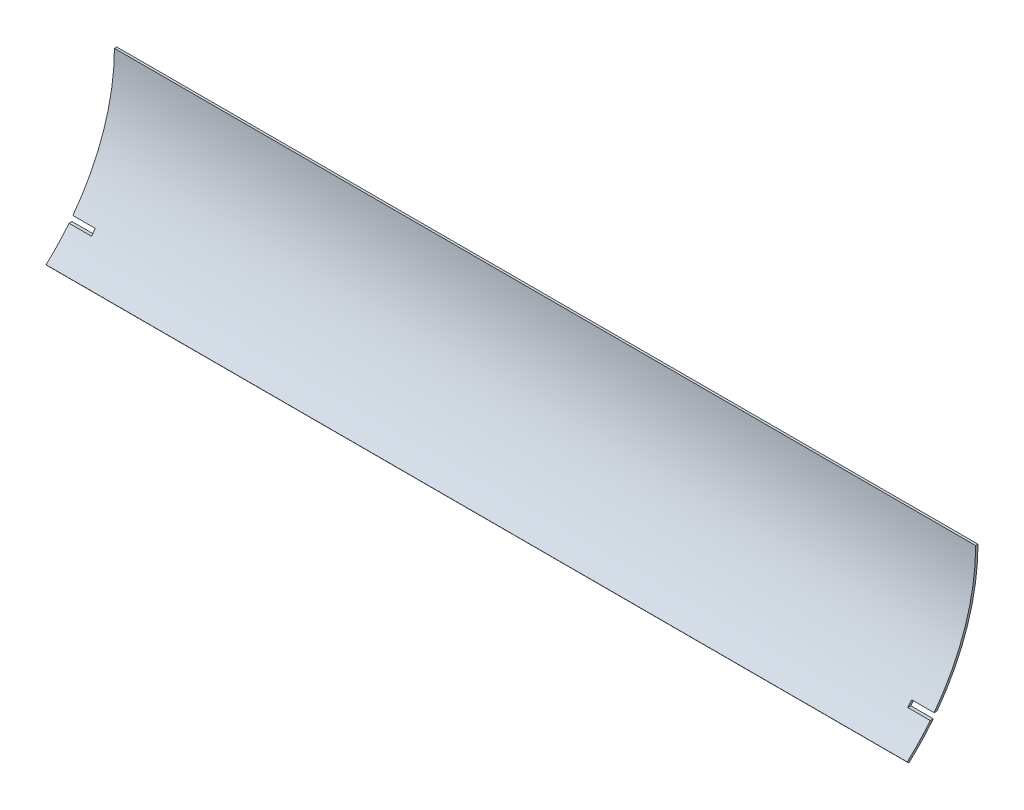
from build123d import *

# Parameters (mm, degrees)
EXTRUDE_THIN1_DEPTH = 584.2
SKETCH3_W           = 15.24
SKETCH3_H           = 3.302
CUT_EXTRUDE1_DEPTH  = 142.12875


with BuildPart() as part:
    # Sketch2 → Extrude-Thin1 (new body)
    with BuildSketch(Plane(origin=(0, 0, 0), x_dir=(0, 0, -1), z_dir=(1, 0, 0))):
        with BuildLine():
            ThreePointArc((94.192253267, -105.09587766), (128.861474149, -57.550365391), (141.12875, 0))
            Line((141.12875, 0), (139.54125, 0))
            ThreePointArc((139.54125, 0), (127.411963754, -56.903004701), (93.132722859, -103.913696809))
            Line((93.132722859, -103.913696809), (94.192253267, -105.09587766))
        make_face()
    extrude(amount=EXTRUDE_THIN1_DEPTH)

    # Sketch3 → Cut-Extrude1 (cut, through all)
    with BuildSketch(Plane.XY):
        with Locations((7.62, -85.752696809)):
            Rectangle(SKETCH3_W, SKETCH3_H)
        with Locations((576.58, -85.752696809)):
            Rectangle(SKETCH3_W, SKETCH3_H)
    extrude(amount=-CUT_EXTRUDE1_DEPTH, mode=Mode.SUBTRACT)


solid = part.part
